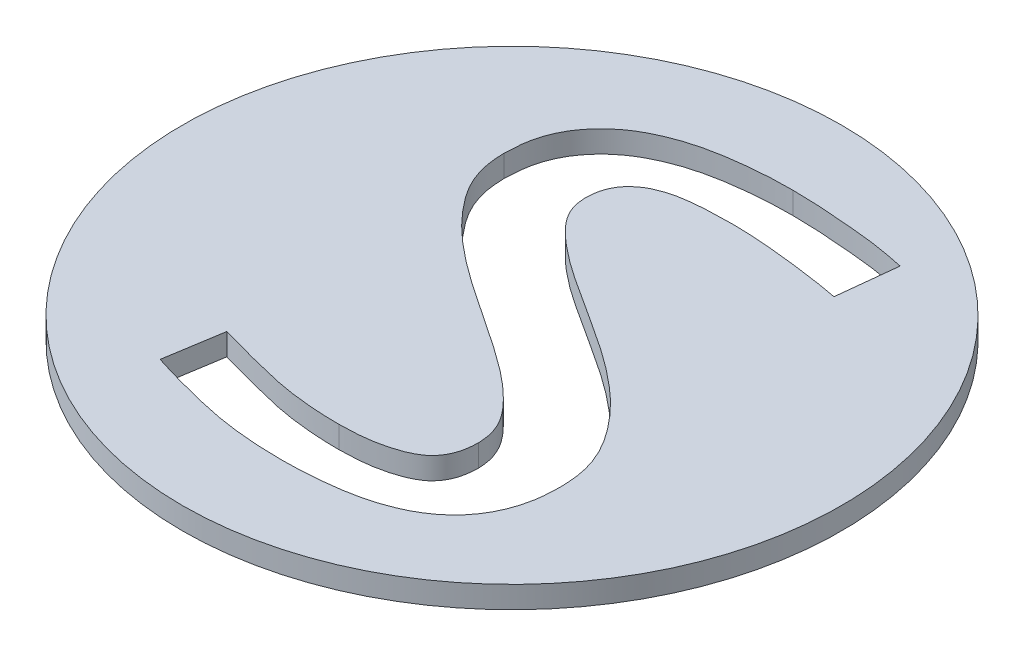
from build123d import *

# Parameters (mm, degrees)
SKETCH1_R           = 45
BOSS_EXTRUDE1_DEPTH = 3


with BuildPart() as part:
    # Sketch1 → Boss-Extrude1 (new body)
    with BuildSketch(Plane(origin=(0, 0, 0), x_dir=(1, 0, 0), z_dir=(0, 1, 0))):
        with Locations(Location((0, 0, 0), (0, 0, 270))):  # turned: the seam where the file's is
            Circle(SKETCH1_R)
        with BuildLine():
            add(Edge.make_bspline(
                [(19.780990946, 24.185124764), (19.255065107, 24.287914798), (18.122086305, 24.509350826), (16.316551627, 24.770179957), (14.357752418, 25.057330128), (12.311058297, 25.302832973), (10.229567608, 25.537930243), (8.173301101, 25.696077882), (6.221913509, 25.819266557), (4.969956895, 25.839869106), (4.377345112, 25.849621292)],
                knots=[0, 0, 0, 0, 0.829036243, 1.785956155, 2.822045536, 3.89228551, 4.975307857, 6.062841547, 7.083048955, 8, 8, 8, 8], degree=3))
            add(Edge.make_bspline(
                [(4.377345112, 25.849621292), (3.446204146, 25.839565028), (1.65716034, 25.820243466), (-0.523497459, 25.678422406), (-2.134814502, 25.466621363), (-3.234258723, 25.269743374), (-4.239722547, 24.96405185), (-5.163089497, 24.614993657), (-6.002431575, 24.201660489), (-6.733506828, 23.675895663), (-7.383141898, 23.092997796), (-7.930081052, 22.419543279), (-8.359935091, 21.657367799), (-8.673790899, 20.796588784), (-8.856015855, 19.829357364), (-8.873240581, 19.150114951), (-8.882203499, 18.796669903)],
                knots=[0, 0, 0, 0, 2.295489194, 4.410428573, 5.380894891, 6.301560079, 7.159764947, 7.966985716, 8.734184816, 9.457764993, 10.179765198, 10.880326743, 11.586237622, 12.32697511, 13.129438398, 14, 14, 14, 14], degree=3))
            add(Edge.make_bspline(
                [(-8.882203499, 18.796669903), (-8.850818027, 18.360202528), (-8.787076829, 17.473774773), (-8.299529285, 16.177773231), (-7.531705877, 14.918174723), (-6.468835972, 13.707430879), (-5.199588079, 12.505820488), (-3.750460779, 11.316874284), (-2.173501164, 10.095772106), (0.19047217, 8.465461016), (3.392591141, 6.389097084), (7.401158074, 3.84423487), (11.436980484, 1.154437496), (14.598547163, -1.337138932), (16.941188197, -3.441782617), (18.524295541, -5.116615111), (19.962389169, -6.861115679), (21.249269366, -8.677300905), (22.30079899, -10.59536019), (23.087128729, -12.62347507), (23.521482235, -14.771077168), (23.585470219, -16.235887567), (23.617796501, -16.975899541)],
                knots=[0, 0, 0, 0, 0.519213468, 1.054477964, 1.630134935, 2.270161266, 2.967727746, 3.71175636, 4.503051278, 5.34407491, 7.13300234, 9.051150551, 11.003302341, 12.910294161, 13.842483047, 14.754150315, 15.653890787, 16.535313878, 17.40293064, 18.254252337, 19.118060482, 20, 20, 20, 20], degree=3))
            add(Edge.make_bspline(
                [(23.617796501, -16.975899541), (23.599786365, -17.672825423), (23.564928796, -19.021684862), (23.270802134, -20.965503255), (22.762650283, -22.748577872), (22.050483541, -24.36572214), (21.174041496, -25.835244154), (20.110888209, -27.14506), (18.897414426, -28.327096204), (17.50009469, -29.336609406), (15.962883146, -30.226180167), (14.258614821, -30.943249705), (12.420117395, -31.575353637), (10.428945987, -32.043245685), (8.315670511, -32.386430983), (6.098422851, -32.63922249), (3.77777338, -32.797342644), (2.195888092, -32.819567974), (1.386893723, -32.830934264)],
                knots=[0, 0, 0, 0, 1.075194104, 2.080975546, 3.024934148, 3.928271024, 4.800677613, 5.657461563, 6.524782954, 7.407242198, 8.310928775, 9.259978089, 10.255920614, 11.308444205, 12.411965724, 13.558733007, 14.751507922, 16, 16, 16, 16], degree=3))
            add(Edge.make_bspline(
                [(1.386893723, -32.830934264), (0.384854835, -32.819567929), (-1.579565413, -32.797285102), (-4.469689043, -32.557780783), (-7.246791058, -32.207577643), (-9.885005378, -31.670272649), (-12.368606742, -31.076733402), (-14.681000089, -30.469055859), (-16.813387105, -29.868409154), (-18.164915503, -29.439515535), (-18.812759054, -29.233929055)],
                knots=[0, 0, 0, 0, 1.166641361, 2.287110747, 3.375174177, 4.42434953, 5.420457035, 6.34882319, 7.208522552, 8, 8, 8, 8], degree=3))
            Line((-18.812759054, -29.233929055), (-17.557333707, -21.391047111))
            add(Edge.make_bspline(
                [(-17.557333707, -21.391047111), (-16.92765023, -21.571066227), (-15.623509008, -21.943904896), (-13.597987784, -22.494044975), (-11.428021788, -23.040422446), (-9.137280734, -23.613361679), (-6.72469763, -24.121615317), (-4.205720245, -24.443757714), (-1.60294269, -24.668864111), (0.163871673, -24.693436806), (1.062457959, -24.705934264)],
                knots=[0, 0, 0, 0, 0.82784923, 1.714563499, 2.653014331, 3.656340952, 4.699592855, 5.767128945, 6.864381369, 8, 8, 8, 8], degree=3))
            add(Edge.make_bspline(
                [(1.062457959, -24.705934264), (1.876650637, -24.687246807), (3.435097114, -24.651477141), (5.663708681, -24.375253087), (7.66548934, -23.896733066), (9.185584763, -23.345151534), (10.24171498, -22.753709402), (10.937316717, -22.248785046), (11.499265321, -21.629257743), (11.979043163, -20.941428467), (12.342776891, -20.163357249), (12.596885499, -19.297650342), (12.751136892, -18.354355508), (12.773133718, -17.695897336), (12.784463168, -17.356758916)],
                knots=[0, 0, 0, 0, 1.865164993, 3.57011294, 5.132569067, 6.57499646, 7.255114939, 7.901464084, 8.534112646, 9.161604161, 9.81695743, 10.491765748, 11.223185006, 12, 12, 12, 12], degree=3))
            add(Edge.make_bspline(
                [(12.784463168, -17.356758916), (12.752373418, -16.859917427), (12.687880197, -15.861377146), (12.224204459, -14.388468451), (11.462465357, -12.964292087), (10.390925154, -11.60553121), (9.124414869, -10.267841999), (7.686118718, -8.936597872), (6.095227969, -7.612559939), (3.717571546, -5.85406476), (0.52885577, -3.635742908), (-3.489713573, -1.025376634), (-7.505368863, 1.697395276), (-10.696639338, 4.119771578), (-13.043162038, 6.168454152), (-14.637770832, 7.740654265), (-16.064077212, 9.372166101), (-17.348452609, 11.025867113), (-18.42180964, 12.766347784), (-19.168862671, 14.625642809), (-19.624536603, 16.58376369), (-19.684854205, 17.919645128), (-19.715536832, 18.599187264)],
                knots=[0, 0, 0, 0, 0.591380666, 1.188542884, 1.822507787, 2.505918877, 3.243027329, 4.015898054, 4.839248524, 5.707487546, 7.538026587, 9.466039613, 11.415971731, 13.317280673, 14.234172866, 15.125381555, 15.982728632, 16.814024653, 17.618094752, 18.409678073, 19.191027939, 20, 20, 20, 20], degree=3))
            add(Edge.make_bspline(
                [(-19.715536832, 18.599187264), (-19.69007572, 19.296431103), (-19.640869758, 20.643919536), (-19.294531368, 22.582084159), (-18.679144546, 24.338232741), (-17.842869563, 25.923663704), (-16.779110741, 27.326321286), (-15.558622534, 28.586881396), (-14.182283058, 29.714351392), (-12.623789919, 30.673268851), (-10.917968821, 31.496846545), (-9.069476595, 32.208414475), (-7.081002803, 32.779480609), (-4.958515074, 33.227140213), (-2.733752509, 33.556420942), (-0.422428367, 33.79150112), (1.95338712, 33.958539874), (3.563608319, 33.969222666), (4.377345112, 33.974621292)],
                knots=[0, 0, 0, 0, 1.03838471, 2.006774832, 2.919286264, 3.799627568, 4.665221273, 5.531947435, 6.40804449, 7.307755042, 8.250508454, 9.225938019, 10.254284747, 11.328399385, 12.454517948, 13.602227205, 14.788268378, 16, 16, 16, 16], degree=3))
            add(Edge.make_bspline(
                [(4.377345112, 33.974621292), (5.110989126, 33.965254351), (6.607281613, 33.946150149), (8.869481458, 33.827722709), (11.14014177, 33.657276118), (13.354931043, 33.460072759), (15.4510663, 33.250532473), (17.378136504, 32.963398675), (19.099276185, 32.65905252), (20.171790498, 32.430381936), (20.669662821, 32.324230667)],
                knots=[0, 0, 0, 0, 1.073469456, 2.189378298, 3.313843796, 4.405133658, 5.442979297, 6.395522168, 7.255184668, 8, 8, 8, 8], degree=3))
            Line((20.669662821, 32.324230667), (19.780990946, 24.185124764))
        make_face(mode=Mode.SUBTRACT)
    extrude(amount=BOSS_EXTRUDE1_DEPTH)


solid = part.part
